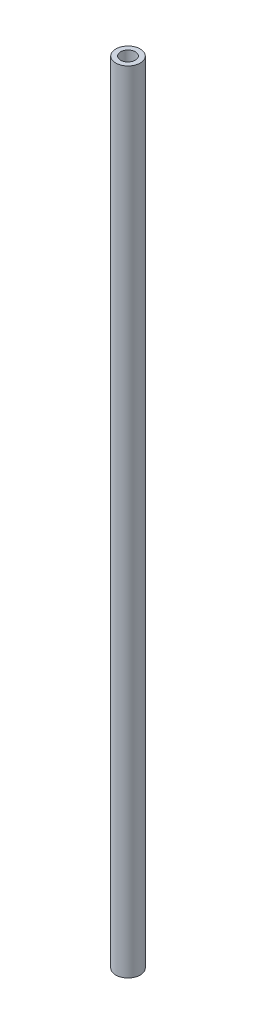
from build123d import *

# Parameters (mm, degrees)
SKETCH_1_R      = 5
SKETCH_1_R_2    = 3
EXTRUDE_1_DEPTH = 323


with BuildPart() as part:
    # 草图1 → 凸台-拉伸1 (new body)
    with BuildSketch(Plane(origin=(0, 0, 0), x_dir=(1, 0, 0), z_dir=(0, 1, 0))):
        Circle(SKETCH_1_R)
        Circle(SKETCH_1_R_2, mode=Mode.SUBTRACT)
    extrude(amount=EXTRUDE_1_DEPTH)


solid = part.part
